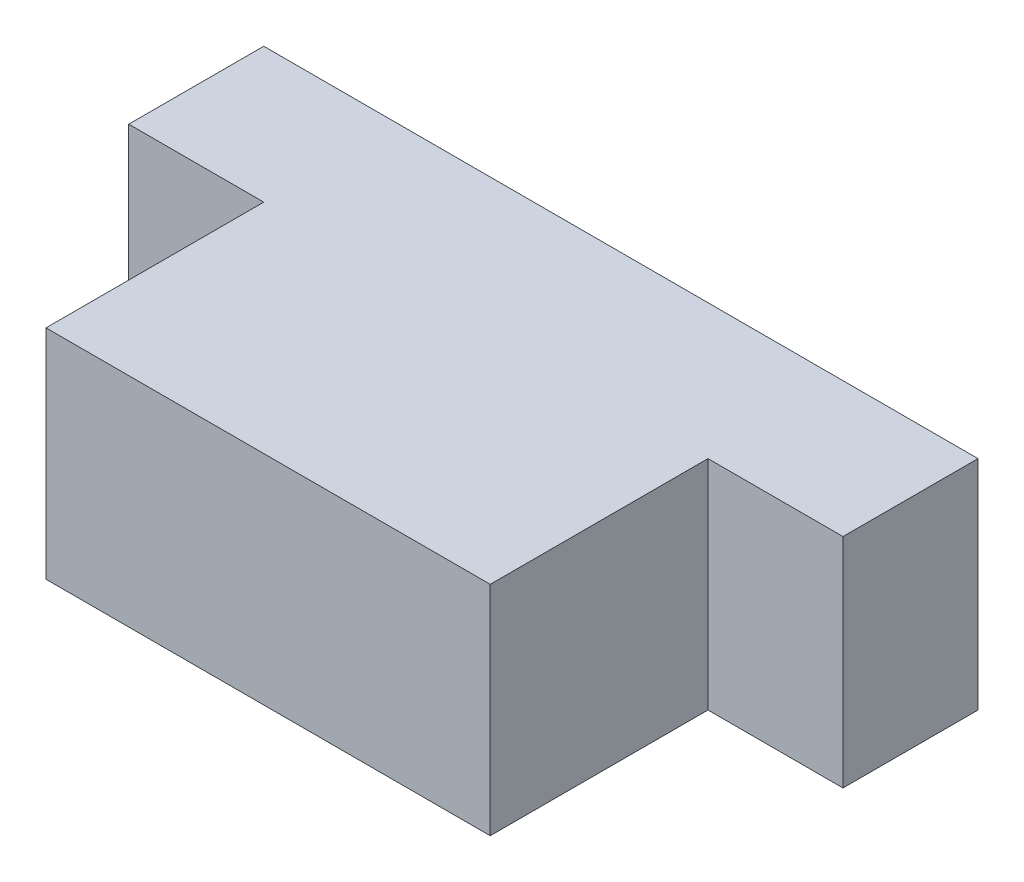
from build123d import *

# Parameters (mm, degrees)
EXTRUDE_1_DEPTH = 5


with BuildPart() as part:
    # 草图1 → 凸台-拉伸1 (new body)
    with BuildSketch(Plane(origin=(0, 0, 0), x_dir=(1, 0, 0), z_dir=(0, 1, 0))):
        Polygon((0, 5), (0, 0), (10.2, 0), (10.2, 5), (13.3, 5), (13.3, 8.1), (-3.1, 8.1), (-3.1, 5), align=None)
    extrude(amount=EXTRUDE_1_DEPTH)


solid = part.part
